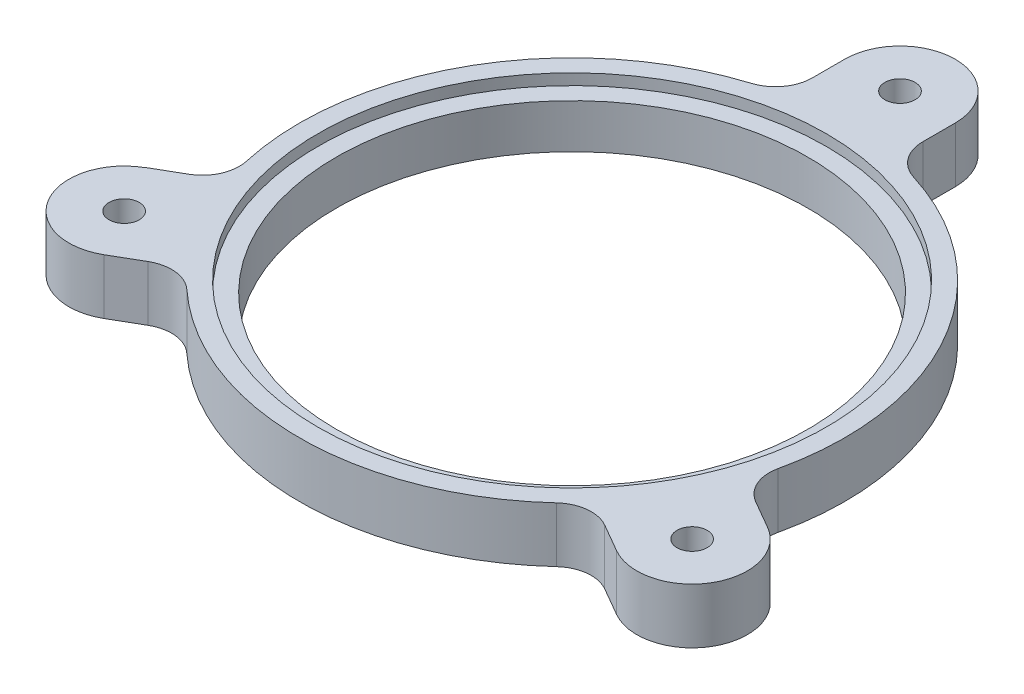
from build123d import *

# Parameters (mm, degrees)
SKETCH1_R           = 69
SKETCH1_R_2         = 4.1
BOSS_EXTRUDE1_DEPTH = 15
SKETCH2_R           = 69
SKETCH2_R_2         = 64
BOSS_EXTRUDE5_DEPTH = 12


with BuildPart() as part:
    # Sketch1 → Boss-Extrude1 (new body)
    with BuildSketch(Plane(origin=(0, 0, 0), x_dir=(1, 0, 0), z_dir=(0, 1, 0))):
        with BuildLine():
            Line((84.576260937, -31.509618943), (76.949622029, -27.106376917))
            ThreePointArc((76.949622029, -27.106376917), (72.790004977, -22.458779787), (72.193714645, -16.25015587))
            ThreePointArc((72.193714645, -16.25015587), (64.08587988, 37), (22.023809524, 70.646668811))
            ThreePointArc((22.023809524, 70.646668811), (16.945128655, 74.267383345), (15, 80.193515947))
            Line((15, 80.193515947), (15, 89))
            ThreePointArc((15, 89), (0, 104), (-15, 89))
            Line((-15, 89), (-15, 80.193515947))
            ThreePointArc((-15, 80.193515947), (-16.945128655, 74.267383345), (-22.023809524, 70.646668811))
            ThreePointArc((-22.023809524, 70.646668811), (-64.071073413, 37.025633711), (-72.206692839, -16.192390475))
            ThreePointArc((-72.206692839, -16.192390475), (-72.806342922, -22.396872115), (-76.964354033, -27.040805388))
            Line((-76.964354033, -27.040805388), (-84.608337243, -31.454061152))
            Line((-84.608337243, -31.454061152), (-84.576260937, -31.509618943))
            ThreePointArc((-84.576260937, -31.509618943), (-90.066641994, -52), (-69.576260937, -57.490381057))
            Line((-69.576260937, -57.490381057), (-61.949622029, -53.08713903))
            ThreePointArc((-61.949622029, -53.08713903), (-55.844876322, -51.808603558), (-50.169905121, -54.396512941))
            ThreePointArc((-50.169905121, -54.396512941), (0, -74), (50.169905121, -54.396512941))
            ThreePointArc((50.169905121, -54.396512941), (55.844876322, -51.808603558), (61.949622029, -53.08713903))
            Line((61.949622029, -53.08713903), (69.576260937, -57.490381057))
            ThreePointArc((69.576260937, -57.490381057), (90.066641994, -52), (84.576260937, -31.509618943))
        make_face()
        Circle(SKETCH1_R, mode=Mode.SUBTRACT)
        with Locations((-77.076260937, -44.5)):
            Circle(SKETCH1_R_2, mode=Mode.SUBTRACT)
        with Locations((77.076260937, -44.5)):
            Circle(SKETCH1_R_2, mode=Mode.SUBTRACT)
        with Locations((0, 89)):
            Circle(SKETCH1_R_2, mode=Mode.SUBTRACT)
    extrude(amount=BOSS_EXTRUDE1_DEPTH)

    # Sketch2 → Boss-Extrude5 (add)
    with BuildSketch(Plane(origin=(0, 0, 0), x_dir=(1, 0, 0), z_dir=(0, 1, 0))):
        Circle(SKETCH2_R)
        Circle(SKETCH2_R_2, mode=Mode.SUBTRACT)
    extrude(amount=BOSS_EXTRUDE5_DEPTH)


solid = part.part
